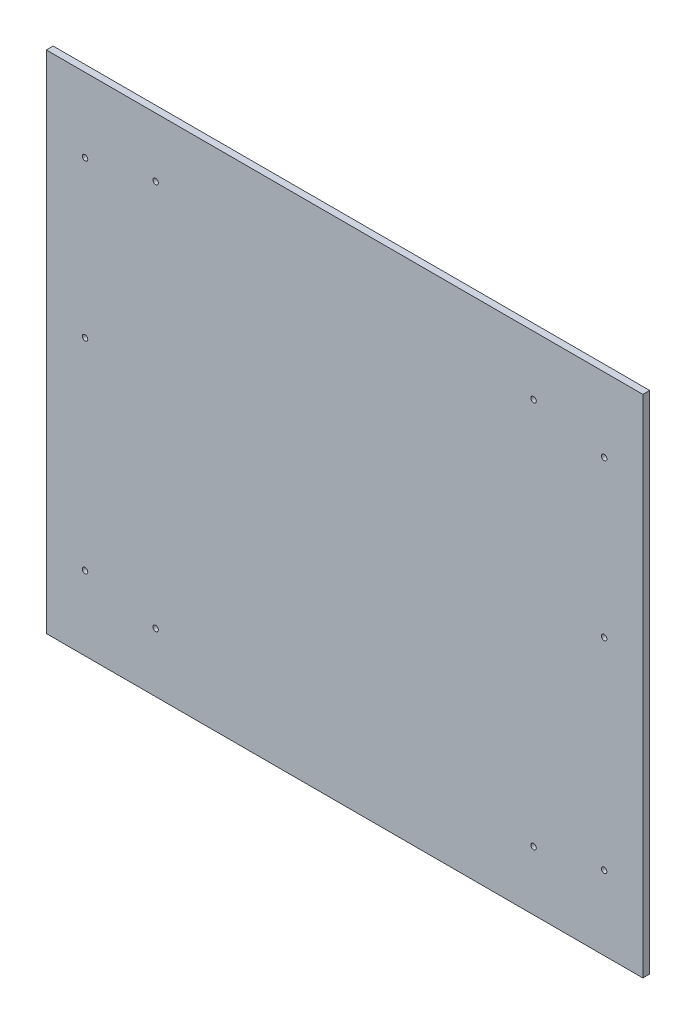
from build123d import *

# Parameters (mm, degrees)
SKETCH1_W           = 415.925
SKETCH1_H           = 352.425
BOSS_EXTRUDE1_DEPTH = 4.7625
SKETCH2_R           = 1.905
CUT_EXTRUDE1_DEPTH  = 546.178564927
SKETCH3_W           = 1.187532467
SKETCH3_H           = 0.445324675
CUT_EXTRUDE2_DEPTH  = 1.016


with BuildPart() as part:
    # Sketch1 → Boss-Extrude1 (new body)
    with BuildSketch(Plane.XY):
        with Locations((207.9625, 176.2125)):
            Rectangle(SKETCH1_W, SKETCH1_H)
    extrude(amount=BOSS_EXTRUDE1_DEPTH)

    # Sketch2 → Cut-Extrude1 (cut, through all)
    with BuildSketch(Plane.XY.offset(4.7625)):
        with Locations((26.9875, 300.8376)):
            Circle(SKETCH2_R)
        with Locations((76.2, 311.15)):
            Circle(SKETCH2_R)
        with Locations((339.725, 311.15)):
            Circle(SKETCH2_R)
        with Locations((388.9375, 300.8376)):
            Circle(SKETCH2_R)
        with Locations((388.9375, 51.5874)):
            Circle(SKETCH2_R)
        with Locations((339.725, 41.275)):
            Circle(SKETCH2_R)
        with Locations((76.2, 41.275)):
            Circle(SKETCH2_R)
        with Locations((26.9875, 51.5874)):
            Circle(SKETCH2_R)
        with Locations((388.9375, 192.1129)):
            Circle(SKETCH2_R)
        with Locations((26.9875, 192.1129)):
            Circle(SKETCH2_R)
    extrude(amount=-CUT_EXTRUDE1_DEPTH, mode=Mode.SUBTRACT)

    # Sketch3 → Cut-Extrude2 (cut)
    # profile 1 of 9: a face of its own
    with BuildSketch(Plane(origin=(0, 0, 0), x_dir=(-1, 0, 0), z_dir=(0, 0, -1))):
        with BuildLine():
            Line((-393.477337662, 342.759805195), (-393.477337662, 342.314480519))
            Line((-393.477337662, 342.314480519), (-395.506038961, 342.314480519))
            Line((-395.506038961, 342.314480519), (-395.506038961, 342.678626218))
            add(Edge.make_bspline(
                [(-395.506038961, 342.678626218), (-395.468398346, 342.729019781), (-395.391782626, 342.831593536), (-395.284642845, 342.995673671), (-395.180422941, 343.170411517), (-395.079134516, 343.35600437), (-394.981583276, 343.552757436), (-394.888439984, 343.760919034), (-394.798032534, 343.97984088), (-394.711299039, 344.207616848), (-394.630477833, 344.440759504), (-394.55861644, 344.675716266), (-394.49597565, 344.91044796), (-394.441784713, 345.144266238), (-394.39669102, 345.377624633), (-394.361230922, 345.610266071), (-394.33456031, 345.842641641), (-394.323851606, 345.997636362), (-394.318506494, 346.075)],
                knots=[0, 0, 0, 0, 0.828261285, 1.685887316, 2.579428271, 3.507501538, 4.469891598, 5.471065063, 6.510494938, 7.589089173, 8.680758398, 9.759817177, 10.82439165, 11.879940066, 12.920405774, 13.953938893, 14.978734705, 16, 16, 16, 16], degree=3))
            Line((-394.318506494, 346.075), (-393.922662338, 346.075))
            add(Edge.make_bspline(
                [(-393.922662338, 346.075), (-393.923986875, 346.034272503), (-393.926688347, 345.951206427), (-393.935072611, 345.824025376), (-393.949326583, 345.692062706), (-393.967885476, 345.55490528), (-393.991404903, 345.412963241), (-394.018115378, 345.265605514), (-394.050907603, 345.113622009), (-394.100262012, 344.904734731), (-394.17074871, 344.643569495), (-394.27199359, 344.335686313), (-394.386514382, 344.034985204), (-394.516465343, 343.744978733), (-394.653360159, 343.468424866), (-394.799935537, 343.212349388), (-394.947877923, 342.975021715), (-395.057095573, 342.830209652), (-395.110194805, 342.759805195)],
                knots=[0, 0, 0, 0, 0.547564817, 1.116789984, 1.712252562, 2.330831182, 2.976456312, 3.645516887, 4.343080939, 5.06547646, 6.529779861, 7.976466419, 9.419056042, 10.851576025, 12.245448489, 13.563727135, 14.815537433, 16, 16, 16, 16], degree=3))
            Line((-395.110194805, 342.759805195), (-393.477337662, 342.759805195))
        make_face()
    # profile 2 of 9: a face of its own
    with BuildSketch(Plane(origin=(0, 0, 0), x_dir=(-1, 0, 0), z_dir=(0, 0, -1))):
        with BuildLine():
            add(Edge.make_bspline(
                [(-391.052792208, 344.171546266), (-391.053420715, 344.093699787), (-391.054641124, 343.942540647), (-391.067256497, 343.723301933), (-391.087149192, 343.518482439), (-391.114218375, 343.328364953), (-391.150793557, 343.152893483), (-391.194120683, 342.991644432), (-391.246712232, 342.845069518), (-391.306601422, 342.713050189), (-391.374560688, 342.596099933), (-391.450819943, 342.494586722), (-391.534285551, 342.40767642), (-391.626667681, 342.337164287), (-391.726552425, 342.282486391), (-391.834148586, 342.243392942), (-391.949369475, 342.219741214), (-392.028889021, 342.216945789), (-392.069462256, 342.215519481)],
                knots=[0, 0, 0, 0, 1.522177082, 2.955701814, 4.292601031, 5.54555501, 6.7088804, 7.795771162, 8.808034672, 9.750647735, 10.627079958, 11.44753433, 12.228026558, 12.97593222, 13.711165822, 14.446140298, 15.20717461, 16, 16, 16, 16], degree=3))
            add(Edge.make_bspline(
                [(-392.069462256, 342.215519481), (-392.105642693, 342.216567003), (-392.176739531, 342.21862545), (-392.279973317, 342.239008477), (-392.377862811, 342.269394275), (-392.468984327, 342.314236048), (-392.55436888, 342.371331992), (-392.633001901, 342.441570068), (-392.706918017, 342.52345493), (-392.749005246, 342.585549567), (-392.770693994, 342.617548701)],
                knots=[0, 0, 0, 0, 1.02455918, 2.013323352, 2.972239719, 3.92313388, 4.881632631, 5.875512573, 6.905191138, 8, 8, 8, 8], degree=3))
            add(Edge.make_bspline(
                [(-392.770693994, 342.617548701), (-392.795879312, 342.660607774), (-392.848254839, 342.750153658), (-392.910673824, 342.900213857), (-392.963883516, 343.067875275), (-393.006388354, 343.253938447), (-393.04008333, 343.457665173), (-393.064541668, 343.679339462), (-393.079238458, 343.919303924), (-393.080723796, 344.085448953), (-393.081493506, 344.171546266)],
                knots=[0, 0, 0, 0, 0.745775943, 1.550919754, 2.425386613, 3.375801173, 4.404149056, 5.513981972, 6.711731112, 8, 8, 8, 8], degree=3))
            add(Edge.make_bspline(
                [(-393.081493506, 344.171546266), (-393.080870707, 344.24887833), (-393.079661616, 344.399009333), (-393.066960997, 344.616947571), (-393.047257801, 344.82077224), (-393.019650346, 345.010206705), (-392.984725408, 345.185471836), (-392.94047718, 345.346058322), (-392.889369572, 345.492789155), (-392.828997488, 345.624782088), (-392.761211678, 345.742244526), (-392.685557467, 345.84462891), (-392.600986329, 345.930654352), (-392.509487754, 346.002238222), (-392.408879891, 346.056674505), (-392.30130294, 346.096702061), (-392.185417991, 346.120268722), (-392.105649672, 346.123054653), (-392.064823458, 346.124480519)],
                knots=[0, 0, 0, 0, 1.513837482, 2.938935398, 4.272350439, 5.521752746, 6.68539866, 7.768673685, 8.780403913, 9.72410058, 10.605895827, 11.431327849, 12.209109083, 12.960945015, 13.697023823, 14.439318735, 15.201227913, 16, 16, 16, 16], degree=3))
            add(Edge.make_bspline(
                [(-392.064823458, 346.124480519), (-392.028403992, 346.123100238), (-391.956799224, 346.12038645), (-391.851879205, 346.100183178), (-391.752726503, 346.064299756), (-391.657719045, 346.016766518), (-391.56914014, 345.953425301), (-391.484609493, 345.878107789), (-391.40715652, 345.787206252), (-391.332347064, 345.683809362), (-391.265619672, 345.562527587), (-391.207827833, 345.422247349), (-391.159647217, 345.262123745), (-391.120897538, 345.082084112), (-391.090477628, 344.882476603), (-391.068271547, 344.663164253), (-391.055420146, 344.423999736), (-391.053691068, 344.257895447), (-391.052792208, 344.171546266)],
                knots=[0, 0, 0, 0, 0.713939269, 1.403684939, 2.084525483, 2.776045801, 3.479790818, 4.213328499, 4.990539752, 5.816442109, 6.712155869, 7.697513436, 8.78604652, 9.986360954, 11.305640346, 12.743160741, 14.306934742, 16, 16, 16, 16], degree=3))
        make_face()
        with BuildLine():
            add(Edge.make_bspline(
                [(-391.448636364, 344.17), (-391.449334298, 344.244225623), (-391.450669983, 344.386276111), (-391.457825727, 344.589758809), (-391.471645679, 344.773893567), (-391.490568084, 344.939050338), (-391.514886695, 345.085218557), (-391.544195101, 345.212688846), (-391.580159922, 345.320708809), (-391.621611944, 345.411166001), (-391.668282306, 345.486311397), (-391.716859016, 345.55110259), (-391.768812868, 345.60589696), (-391.824296426, 345.650465114), (-391.882579843, 345.68594172), (-391.944435843, 345.710881333), (-392.009437018, 345.726240174), (-392.053915462, 345.727831296), (-392.076420455, 345.728636364)],
                knots=[0, 0, 0, 0, 1.930680258, 3.694870612, 5.294765573, 6.732327541, 8.017244644, 9.14720992, 10.130763445, 10.973463911, 11.728776188, 12.427251247, 13.076760965, 13.687074849, 14.273357039, 14.844695938, 15.415444712, 16, 16, 16, 16], degree=3))
            add(Edge.make_bspline(
                [(-392.076420455, 345.728636364), (-392.097663352, 345.727905634), (-392.139961343, 345.726450636), (-392.201587006, 345.709676651), (-392.260921972, 345.685381714), (-392.316892401, 345.649190245), (-392.369934752, 345.603459923), (-392.420528422, 345.547719639), (-392.468395258, 345.482424333), (-392.514025281, 345.406248849), (-392.555919294, 345.315460741), (-392.590388363, 345.206521853), (-392.620440655, 345.079400574), (-392.643390255, 344.933536831), (-392.662751439, 344.769276411), (-392.676403618, 344.5861446), (-392.683621667, 344.384216791), (-392.684954074, 344.243453199), (-392.685649351, 344.17)],
                knots=[0, 0, 0, 0, 0.5561996, 1.107481919, 1.665324653, 2.233973471, 2.848122302, 3.499305928, 4.205575626, 4.970121907, 5.826722289, 6.823612291, 7.963984009, 9.252947287, 10.697030014, 12.304913753, 14.07183163, 16, 16, 16, 16], degree=3))
            add(Edge.make_bspline(
                [(-392.685649351, 344.17), (-392.684945534, 344.0957747), (-392.683596153, 343.953467315), (-392.67649858, 343.749723114), (-392.662578115, 343.565083176), (-392.643786994, 343.399651768), (-392.619387068, 343.253240013), (-392.590111314, 343.125751858), (-392.554066715, 343.017783878), (-392.512942511, 342.927370328), (-392.465679103, 342.852884787), (-392.41773459, 342.787852373), (-392.364395629, 342.734071922), (-392.308566737, 342.689729284), (-392.249994535, 342.653852032), (-392.187270103, 342.629006327), (-392.121215605, 342.6138322), (-392.075984688, 342.612189947), (-392.053226461, 342.611363636)],
                knots=[0, 0, 0, 0, 1.926017154, 3.692628624, 5.288659415, 6.729390826, 8.011204514, 9.138440624, 10.119618606, 10.960283728, 11.708082919, 12.404870975, 13.05267392, 13.666742433, 14.251608596, 14.827770794, 15.41018532, 16, 16, 16, 16], degree=3))
            add(Edge.make_bspline(
                [(-392.053226461, 342.611363636), (-392.031986838, 342.612089224), (-391.989945701, 342.613525433), (-391.928963675, 342.630097844), (-391.870589843, 342.655255423), (-391.814707213, 342.690327311), (-391.761810988, 342.735835512), (-391.71220374, 342.791553552), (-391.665200027, 342.857041397), (-391.619265594, 342.933118907), (-391.577807171, 343.024042424), (-391.543910549, 343.133052355), (-391.513988764, 343.260142847), (-391.489672903, 343.406071812), (-391.471925113, 343.570801974), (-391.457760773, 343.753840314), (-391.450698924, 343.955787546), (-391.449343599, 344.096548288), (-391.448636364, 344.17)],
                knots=[0, 0, 0, 0, 0.557130238, 1.102768586, 1.649079731, 2.224414864, 2.830037934, 3.477754783, 4.181203309, 4.947028836, 5.811221183, 6.801235864, 7.943515661, 9.242435973, 10.688157038, 12.298731102, 14.068605401, 16, 16, 16, 16], degree=3))
        make_face(mode=Mode.SUBTRACT)
    # profile 3 of 9: a face of its own
    with BuildSketch(Plane(origin=(0, 0, 0), x_dir=(-1, 0, 0), z_dir=(0, 0, -1))):
        with BuildLine():
            Line((-390.607467532, 343.155649351), (-390.211623377, 343.20512987))
            add(Edge.make_bspline(
                [(-390.211623377, 343.20512987), (-390.202473465, 343.160047347), (-390.18533987, 343.075628425), (-390.148177301, 342.961267534), (-390.106771331, 342.865650808), (-390.06848073, 342.814915331), (-390.050811688, 342.791503653)],
                knots=[0, 0, 0, 0, 1.230211225, 2.30362229, 3.217213433, 4, 4, 4, 4], degree=3))
            add(Edge.make_bspline(
                [(-390.050811688, 342.791503653), (-390.037964368, 342.777036853), (-390.012983773, 342.748907309), (-389.971432824, 342.712528789), (-389.928595753, 342.680818907), (-389.883275657, 342.655665045), (-389.835878281, 342.635707963), (-389.786480356, 342.622120171), (-389.735171455, 342.613252157), (-389.700361104, 342.611996884), (-389.682800325, 342.611363636)],
                knots=[0, 0, 0, 0, 1.095058468, 2.129254274, 3.122126386, 4.109077278, 5.058043602, 6.028662132, 7.005519128, 8, 8, 8, 8], degree=3))
            add(Edge.make_bspline(
                [(-389.682800325, 342.611363636), (-389.655598097, 342.612372919), (-389.601705009, 342.614372511), (-389.523494826, 342.635930105), (-389.449038837, 342.668299898), (-389.37937846, 342.715115777), (-389.314380823, 342.774722044), (-389.252662681, 342.846556458), (-389.196545262, 342.932267966), (-389.163968139, 342.995292364), (-389.147019075, 343.028082386)],
                knots=[0, 0, 0, 0, 0.906800098, 1.796553483, 2.691003266, 3.610512055, 4.585978966, 5.630213089, 6.767058994, 8, 8, 8, 8], degree=3))
            add(Edge.make_bspline(
                [(-389.147019075, 343.028082386), (-389.132799324, 343.059556936), (-389.103236151, 343.124993211), (-389.068465249, 343.231608912), (-389.038363557, 343.348595762), (-389.01390063, 343.476443857), (-388.994820575, 343.614775065), (-388.981076185, 343.763880324), (-388.97256513, 343.923529559), (-388.971363472, 344.0336599), (-388.970744724, 344.090367289)],
                knots=[0, 0, 0, 0, 0.763483597, 1.587299063, 2.476320726, 3.434428227, 4.464721063, 5.564015708, 6.745683445, 8, 8, 8, 8], degree=3))
            add(Edge.make_bspline(
                [(-388.970744724, 344.090367289), (-388.993158545, 344.051779011), (-389.036771466, 343.976693756), (-389.118029618, 343.878306448), (-389.205455101, 343.79233399), (-389.302259572, 343.723353909), (-389.404047822, 343.668441578), (-389.50978088, 343.629813192), (-389.618545827, 343.605332156), (-389.692208711, 343.602430627), (-389.729188312, 343.600974026)],
                knots=[0, 0, 0, 0, 1.127755568, 2.194392168, 3.218534893, 4.223278226, 5.192146243, 6.137338825, 7.064923014, 8, 8, 8, 8], degree=3))
            add(Edge.make_bspline(
                [(-389.729188312, 343.600974026), (-389.75992013, 343.602043049), (-389.820490571, 343.604150025), (-389.90987178, 343.620095148), (-389.99591496, 343.646611326), (-390.079418744, 343.683078595), (-390.159553132, 343.731036133), (-390.236886956, 343.788971217), (-390.310449804, 343.858081598), (-390.381529738, 343.935353982), (-390.446055146, 344.022397267), (-390.502649131, 344.117222812), (-390.550941798, 344.21883731), (-390.589271134, 344.328140412), (-390.620350571, 344.443832774), (-390.641924268, 344.5669682), (-390.65401193, 344.697032236), (-390.655953734, 344.786162167), (-390.656948052, 344.831801948)],
                knots=[0, 0, 0, 0, 0.860357646, 1.695709716, 2.533583491, 3.377064945, 4.241047709, 5.143225219, 6.077846286, 7.063889573, 8.080111547, 9.106229702, 10.152257742, 11.225204373, 12.345649275, 13.503769734, 14.721782881, 16, 16, 16, 16], degree=3))
            add(Edge.make_bspline(
                [(-390.656948052, 344.831801948), (-390.655369388, 344.89373845), (-390.652276956, 345.015065396), (-390.626365287, 345.192708364), (-390.582723351, 345.361211421), (-390.533307712, 345.494785347), (-390.485731891, 345.594847636), (-390.4480047, 345.664679758), (-390.40725726, 345.729164645), (-390.365468799, 345.789405203), (-390.320067428, 345.844098086), (-390.272324328, 345.893255741), (-390.222449939, 345.938050469), (-390.152831441, 345.989902018), (-390.061307575, 346.044189556), (-389.944067702, 346.090198598), (-389.82183566, 346.1192935), (-389.738111138, 346.122743127), (-389.695943588, 346.124480519)],
                knots=[0, 0, 0, 0, 1.657477552, 3.246820249, 4.792931373, 6.310143579, 7.050773408, 7.757735392, 8.433441671, 9.091881484, 9.719037924, 10.333777231, 10.92503469, 11.511442381, 12.655601843, 13.761194519, 14.872433761, 16, 16, 16, 16], degree=3))
            add(Edge.make_bspline(
                [(-389.695943588, 346.124480519), (-389.657965638, 346.123146599), (-389.583268517, 346.120522971), (-389.473909496, 346.099631205), (-389.369639244, 346.066474311), (-389.270306014, 346.019449958), (-389.176171081, 345.958701956), (-389.088046229, 345.8837132), (-389.004711431, 345.796088497), (-388.925998233, 345.695381479), (-388.855254814, 345.577964477), (-388.79341898, 345.443485106), (-388.74218369, 345.290663853), (-388.699961774, 345.120530549), (-388.668302501, 344.932285776), (-388.64435944, 344.726919625), (-388.630712108, 344.503405603), (-388.629089694, 344.348612267), (-388.628246753, 344.268187906)],
                knots=[0, 0, 0, 0, 0.760776034, 1.496336177, 2.223302797, 2.948873241, 3.69253306, 4.462409234, 5.262555392, 6.112948448, 7.019240997, 8.003827252, 9.073820409, 10.245244624, 11.514025169, 12.897394376, 14.388011526, 16, 16, 16, 16], degree=3))
            add(Edge.make_bspline(
                [(-388.628246753, 344.268187906), (-388.628981258, 344.178995628), (-388.630396168, 344.007180526), (-388.645498674, 343.759302982), (-388.668514021, 343.531328334), (-388.702260558, 343.32314478), (-388.745820755, 343.134944384), (-388.799020458, 342.966265342), (-388.860516465, 342.816764507), (-388.93423961, 342.68772789), (-389.015147646, 342.576880529), (-389.100674292, 342.480235194), (-389.192114975, 342.398909838), (-389.288544539, 342.330888216), (-389.39187051, 342.279924332), (-389.499970775, 342.242078823), (-389.614150271, 342.220215171), (-389.691987696, 342.21710075), (-389.731507711, 342.215519481)],
                knots=[0, 0, 0, 0, 1.648984134, 3.176512383, 4.589967025, 5.884119787, 7.073476536, 8.158525833, 9.151516126, 10.056402341, 10.89896907, 11.685273886, 12.437938781, 13.157016243, 13.860256991, 14.560990922, 15.269378972, 16, 16, 16, 16], degree=3))
            add(Edge.make_bspline(
                [(-389.731507711, 342.215519481), (-389.760140715, 342.216334396), (-389.81658196, 342.217940754), (-389.899618949, 342.228485779), (-389.978735295, 342.248164491), (-390.05423745, 342.274715315), (-390.1268353, 342.307590736), (-390.194813376, 342.350210592), (-390.26027686, 342.398759894), (-390.321123847, 342.455520163), (-390.378192013, 342.518803058), (-390.427936776, 342.590527443), (-390.473122626, 342.667889199), (-390.511880671, 342.752389342), (-390.545009644, 342.843394079), (-390.571761818, 342.941484558), (-390.593855608, 343.045981089), (-390.602850737, 343.118452853), (-390.607467532, 343.155649351)],
                knots=[0, 0, 0, 0, 0.965270463, 1.902736681, 2.815070868, 3.708007483, 4.598108228, 5.495050481, 6.40721921, 7.341661662, 8.295409263, 9.273996573, 10.278274954, 11.312175679, 12.403221606, 13.539269482, 14.737017652, 16, 16, 16, 16], degree=3))
        make_face()
        with BuildLine():
            add(Edge.make_bspline(
                [(-389.024090909, 344.817112419), (-389.024658095, 344.850635702), (-389.025764218, 344.916012686), (-389.035153868, 345.011634583), (-389.050840271, 345.102205589), (-389.070906812, 345.188154757), (-389.099238897, 345.268481961), (-389.133493704, 345.343541033), (-389.17248878, 345.414651166), (-389.219208881, 345.478852972), (-389.268608373, 345.537306851), (-389.321089963, 345.587766945), (-389.374095679, 345.631938641), (-389.430656472, 345.666674389), (-389.48859196, 345.695261546), (-389.549403591, 345.714256462), (-389.61169681, 345.726465359), (-389.653879746, 345.727910462), (-389.675068994, 345.728636364)],
                knots=[0, 0, 0, 0, 1.296144346, 2.527735915, 3.710626612, 4.84906567, 5.936415351, 6.997883046, 8.037465384, 9.066195934, 10.06280824, 10.993087436, 11.878683343, 12.724822989, 13.553888704, 14.370157937, 15.181301027, 16, 16, 16, 16], degree=3))
            add(Edge.make_bspline(
                [(-389.675068994, 345.728636364), (-389.693925955, 345.727824191), (-389.7314327, 345.72620877), (-389.78674129, 345.715337564), (-389.839978825, 345.696059271), (-389.892157517, 345.67061852), (-389.942659641, 345.636897131), (-389.99131128, 345.59557911), (-390.038463566, 345.547293741), (-390.084210532, 345.492757042), (-390.125411859, 345.431223911), (-390.162209104, 345.364094771), (-390.193174133, 345.291365281), (-390.21738709, 345.212664185), (-390.238001663, 345.128906633), (-390.251513396, 345.039377239), (-390.259062051, 344.944295118), (-390.260409666, 344.879234596), (-390.261103896, 344.845718344)],
                knots=[0, 0, 0, 0, 0.772526166, 1.536564769, 2.297899578, 3.086420588, 3.909253034, 4.7784632, 5.696750295, 6.671391525, 7.690425714, 8.72514537, 9.803697274, 10.922277634, 12.095098258, 13.334461535, 14.626834596, 16, 16, 16, 16], degree=3))
            add(Edge.make_bspline(
                [(-390.261103896, 344.845718344), (-390.260412361, 344.812974454), (-390.259070891, 344.749456403), (-390.251497997, 344.656692466), (-390.238116789, 344.569698862), (-390.217297902, 344.488559428), (-390.193168303, 344.412771686), (-390.162919753, 344.34240948), (-390.126330267, 344.278080098), (-390.084971331, 344.219423722), (-390.038882645, 344.167855557), (-389.991418487, 344.121423918), (-389.939599906, 344.083741173), (-389.886664096, 344.051534661), (-389.830580818, 344.027486013), (-389.772438817, 344.009167282), (-389.711210827, 343.999463874), (-389.669685652, 343.997704051), (-389.648782468, 343.996818182)],
                knots=[0, 0, 0, 0, 1.344260104, 2.607655456, 3.818208625, 4.95233668, 6.042998368, 7.080704521, 8.089811597, 9.076145914, 10.020627392, 10.926084953, 11.795728431, 12.644859331, 13.464478827, 14.294411822, 15.14143111, 16, 16, 16, 16], degree=3))
            add(Edge.make_bspline(
                [(-389.648782468, 343.996818182), (-389.628107721, 343.997249999), (-389.587232524, 343.998103727), (-389.52744012, 344.009822359), (-389.469119735, 344.026651267), (-389.413219254, 344.051509021), (-389.35910561, 344.082940854), (-389.30715603, 344.120907458), (-389.257583479, 344.166385393), (-389.209800935, 344.217741885), (-389.166020167, 344.275301239), (-389.127587227, 344.338395433), (-389.096714625, 344.40686728), (-389.068557718, 344.478931254), (-389.049216249, 344.556977772), (-389.034398547, 344.639333892), (-389.025955371, 344.726740339), (-389.024723966, 344.786427587), (-389.024090909, 344.817112419)],
                knots=[0, 0, 0, 0, 0.863254972, 1.706706166, 2.538719029, 3.397725308, 4.257272268, 5.151846783, 6.082689542, 7.066491316, 8.081726413, 9.101982937, 10.148262134, 11.219173362, 12.332727134, 13.503929281, 14.716786026, 16, 16, 16, 16], degree=3))
        make_face(mode=Mode.SUBTRACT)
    # profile 4 of 9: a face of its own
    with BuildSketch(Plane(origin=(0, 0, 0), x_dir=(-1, 0, 0), z_dir=(0, 0, -1))):
        with Locations((-387.737597403, 344.714285715)):
            Rectangle(SKETCH3_W, SKETCH3_H)
    # profile 5 of 9: a face of its own
    with BuildSketch(Plane(origin=(0, 0, 0), x_dir=(-1, 0, 0), z_dir=(0, 0, -1))):
        with BuildLine():
            Line((-384.422402597, 346.075), (-384.422402597, 342.265))
            Line((-384.422402597, 342.265), (-385.596018669, 342.265))
            add(Edge.make_bspline(
                [(-385.596018669, 342.265), (-385.629528361, 342.264967122), (-385.693996001, 342.264903869), (-385.787272264, 342.269486529), (-385.873745587, 342.274019261), (-385.953583162, 342.283112428), (-386.026671742, 342.292614608), (-386.093103244, 342.304847397), (-386.152429123, 342.320182023), (-386.189330738, 342.332580342), (-386.206793831, 342.338447646)],
                knots=[0, 0, 0, 0, 1.301151554, 2.5032211, 3.626367283, 4.663111316, 5.622785769, 6.488454062, 7.284685336, 8, 8, 8, 8], degree=3))
            add(Edge.make_bspline(
                [(-386.206793831, 342.338447646), (-386.228906778, 342.347006422), (-386.273080272, 342.364103693), (-386.335299039, 342.397858945), (-386.394659917, 342.435880865), (-386.450449654, 342.47919156), (-386.502494578, 342.528339334), (-386.55098663, 342.582662641), (-386.597272071, 342.641539723), (-386.638489308, 342.706626788), (-386.676305244, 342.775675377), (-386.709191652, 342.848992032), (-386.735922453, 342.926509397), (-386.758192899, 343.007628667), (-386.776410473, 343.092479295), (-386.788143288, 343.181166043), (-386.796466352, 343.273780541), (-386.797128733, 343.336800264), (-386.797467532, 343.369034091)],
                knots=[0, 0, 0, 0, 0.896949636, 1.791773796, 2.674115289, 3.564138569, 4.461512697, 5.380431273, 6.319235066, 7.293620624, 8.293517089, 9.298115845, 10.331907158, 11.394805857, 12.481795972, 13.614719922, 14.779958068, 16, 16, 16, 16], degree=3))
            add(Edge.make_bspline(
                [(-386.797467532, 343.369034091), (-386.796813064, 343.411329133), (-386.795533078, 343.494048314), (-386.782965582, 343.615035218), (-386.762078809, 343.729747989), (-386.733581034, 343.838737713), (-386.69656993, 343.941839797), (-386.650739821, 344.038783306), (-386.596975716, 344.129915425), (-386.535596254, 344.215406195), (-386.463266447, 344.293223419), (-386.377903141, 344.359795485), (-386.281322129, 344.416732086), (-386.172317742, 344.461987776), (-386.052001893, 344.498542139), (-385.919283808, 344.52346175), (-385.774676288, 344.537894822), (-385.674397369, 344.540006787), (-385.622305195, 344.541103896)],
                knots=[0, 0, 0, 0, 1.066125632, 2.085091685, 3.062630143, 4.003547869, 4.922307223, 5.820454748, 6.703048758, 7.586837887, 8.469431897, 9.371589709, 10.306565591, 11.287746888, 12.340181319, 13.471797101, 14.68666727, 16, 16, 16, 16], degree=3))
            Line((-385.622305195, 344.541103896), (-384.818246753, 344.541103896))
            Line((-384.818246753, 344.541103896), (-384.818246753, 346.075))
            Line((-384.818246753, 346.075), (-384.422402597, 346.075))
        make_face()
        with BuildLine():
            Line((-384.818246753, 344.095779221), (-385.647045455, 344.095779221))
            add(Edge.make_bspline(
                [(-385.647045455, 344.095779221), (-385.678497922, 344.095072553), (-385.739437411, 344.093703376), (-385.827888777, 344.086401224), (-385.90981958, 344.072472093), (-385.985207163, 344.053403979), (-386.053828531, 344.028515848), (-386.116393252, 343.998512377), (-386.172010809, 343.962057606), (-386.221449173, 343.920660111), (-386.264731189, 343.873859832), (-386.300681822, 343.820382937), (-386.333132875, 343.762699455), (-386.357110427, 343.698235357), (-386.377777731, 343.629448083), (-386.391181192, 343.554488089), (-386.399832405, 343.474126569), (-386.401014524, 343.41853911), (-386.401623377, 343.389908685)],
                knots=[0, 0, 0, 0, 1.269253369, 2.459191891, 3.57717208, 4.618751137, 5.592406951, 6.51784041, 7.411898102, 8.267961587, 9.11430795, 9.973837676, 10.862619214, 11.777890835, 12.742005423, 13.757621058, 14.845058537, 16, 16, 16, 16], degree=3))
            add(Edge.make_bspline(
                [(-386.401623377, 343.389908685), (-386.400765806, 343.352718312), (-386.399112226, 343.281007281), (-386.381273378, 343.177539277), (-386.354190387, 343.082180593), (-386.315244634, 342.996077246), (-386.268571331, 342.920992201), (-386.216780718, 342.85717429), (-386.159474957, 342.806928238), (-386.107164851, 342.774014782), (-386.059934659, 342.75559541), (-386.018549051, 342.743364254), (-385.970874141, 342.732297917), (-385.916408282, 342.725562987), (-385.856206146, 342.717951432), (-385.78959763, 342.713934261), (-385.716664451, 342.710456778), (-385.665863933, 342.710370018), (-385.639314123, 342.710324675)],
                knots=[0, 0, 0, 0, 1.499931441, 2.892190131, 4.22555523, 5.492142586, 6.693106624, 7.786754549, 8.796791062, 9.758519433, 10.262760139, 10.83874575, 11.500028322, 12.235695527, 13.052584314, 13.949495096, 14.928347241, 16, 16, 16, 16], degree=3))
            Line((-385.639314123, 342.710324675), (-384.818246753, 342.710324675))
            Line((-384.818246753, 342.710324675), (-384.818246753, 344.095779221))
        make_face(mode=Mode.SUBTRACT)
    # profile 6 of 9: a face of its own
    with BuildSketch(Plane(origin=(0, 0, 0), x_dir=(-1, 0, 0), z_dir=(0, 0, -1))):
        Polygon((-381.156688312, 346.075), (-382.373599838, 342.265), (-382.759393263, 342.265), (-383.977077922, 346.075), (-383.565771104, 346.075), (-383.232550731, 344.936948052), (-381.901215503, 344.936948052), (-381.568768263, 346.075), align=None)
        with BuildLine():
            Line((-382.031101867, 344.491623377), (-383.101891234, 344.491623377))
            Line((-383.101891234, 344.491623377), (-382.78336039, 343.444801136))
            add(Edge.make_bspline(
                [(-382.78336039, 343.444801136), (-382.771453681, 343.405644679), (-382.748207569, 343.329197404), (-382.715129304, 343.21729957), (-382.683955834, 343.110936062), (-382.65533931, 343.010238171), (-382.630030958, 342.915013068), (-382.606510676, 342.825668444), (-382.585807712, 342.741862712), (-382.573024068, 342.687656588), (-382.566883117, 342.661617289)],
                knots=[0, 0, 0, 0, 1.208585302, 2.359586633, 3.44573617, 4.481694954, 5.45087266, 6.355352717, 7.20995158, 8, 8, 8, 8], degree=3))
            add(Edge.make_bspline(
                [(-382.566883117, 342.661617289), (-382.555744256, 342.722273282), (-382.533481332, 342.843504692), (-382.491750358, 343.024101348), (-382.445323383, 343.204372112), (-382.408369221, 343.323303121), (-382.389835633, 343.382950487)],
                knots=[0, 0, 0, 0, 0.995500629, 1.989678841, 2.991765375, 4, 4, 4, 4], degree=3))
            Line((-382.389835633, 343.382950487), (-382.031101867, 344.491623377))
        make_face(mode=Mode.SUBTRACT)
    # profile 7 of 9: a face of its own
    with BuildSketch(Plane(origin=(0, 0, 0), x_dir=(-1, 0, 0), z_dir=(0, 0, -1))):
        with BuildLine():
            Line((-378.48474026, 344.837987013), (-378.880584416, 344.788506494))
            add(Edge.make_bspline(
                [(-378.880584416, 344.788506494), (-378.886331949, 344.838909793), (-378.897232191, 344.934500036), (-378.927375084, 345.068226035), (-378.966719786, 345.184773275), (-379.018287855, 345.28458693), (-379.079638996, 345.371843245), (-379.153468329, 345.447986007), (-379.238303741, 345.515742898), (-379.334324107, 345.573399638), (-379.439064368, 345.620510736), (-379.551214922, 345.654703711), (-379.669977541, 345.675195853), (-379.751308181, 345.677816343), (-379.792881494, 345.679155844)],
                knots=[0, 0, 0, 0, 1.281050936, 2.429522926, 3.457180855, 4.380419844, 5.258532054, 6.142803829, 7.050969554, 7.994650731, 8.965267996, 9.945773918, 10.949953137, 12, 12, 12, 12], degree=3))
            add(Edge.make_bspline(
                [(-379.792881494, 345.679155844), (-379.822541993, 345.678551244), (-379.880184758, 345.677376254), (-379.964132031, 345.668590543), (-380.043154489, 345.65522932), (-380.11704238, 345.634800624), (-380.185965753, 345.60946668), (-380.250032468, 345.578655904), (-380.308243586, 345.540984603), (-380.361663357, 345.498827459), (-380.408656662, 345.451460857), (-380.449980828, 345.401053944), (-380.485116262, 345.347224949), (-380.514167218, 345.289812303), (-380.535093274, 345.228424141), (-380.552092735, 345.164513952), (-380.56117095, 345.09673265), (-380.56232922, 345.050364796), (-380.562922078, 345.026631494)],
                knots=[0, 0, 0, 0, 1.2501121, 2.429491015, 3.554738234, 4.624770363, 5.655989494, 6.647174221, 7.614555715, 8.573174125, 9.51037654, 10.421526264, 11.316469507, 12.215294815, 13.125861444, 14.045456575, 14.999570494, 16, 16, 16, 16], degree=3))
            add(Edge.make_bspline(
                [(-380.562922078, 345.026631494), (-380.562093559, 344.999248947), (-380.560479806, 344.945914399), (-380.546074433, 344.868469165), (-380.523189486, 344.796259476), (-380.49031881, 344.729360381), (-380.447165385, 344.668665642), (-380.394779616, 344.61334418), (-380.333193812, 344.563694586), (-380.273638854, 344.526945624), (-380.216658564, 344.499761383), (-380.16221683, 344.477732576), (-380.097383711, 344.452893541), (-380.021297497, 344.426673176), (-379.934322719, 344.399178774), (-379.836314384, 344.369778314), (-379.727646163, 344.338012805), (-379.651173182, 344.317037002), (-379.611195211, 344.306071429)],
                knots=[0, 0, 0, 0, 1.004942946, 1.957384713, 2.882338134, 3.779759916, 4.683151972, 5.607184727, 6.569546081, 7.580932032, 8.169390295, 8.886581061, 9.73741851, 10.719272822, 11.841835979, 13.087539982, 14.477446005, 16, 16, 16, 16], degree=3))
            add(Edge.make_bspline(
                [(-379.611195211, 344.306071429), (-379.575320658, 344.295941638), (-379.506184865, 344.27641997), (-379.406996258, 344.24529218), (-379.315565666, 344.214594735), (-379.232093159, 344.183259157), (-379.15736306, 344.15052746), (-379.090162914, 344.119087896), (-379.031161023, 344.086722516), (-378.96387237, 344.042833056), (-378.889733026, 343.983265141), (-378.810642346, 343.904209616), (-378.743289932, 343.815103053), (-378.685793505, 343.71831831), (-378.639751145, 343.613563122), (-378.607741291, 343.501182058), (-378.586638412, 343.382454082), (-378.584692647, 343.300833878), (-378.583701299, 343.259249188)],
                knots=[0, 0, 0, 0, 1.11410023, 2.147042836, 3.106741435, 3.996541296, 4.810716634, 5.544561419, 6.213395996, 6.820137826, 7.943677056, 9.049331341, 10.153911915, 11.272794625, 12.407604075, 13.562982632, 14.758363689, 16, 16, 16, 16], degree=3))
            add(Edge.make_bspline(
                [(-378.583701299, 343.259249188), (-378.584554506, 343.221834289), (-378.58623174, 343.148284137), (-378.600551928, 343.040634776), (-378.623245723, 342.93784847), (-378.657126135, 342.841036619), (-378.698519511, 342.748770908), (-378.751264074, 342.662908573), (-378.811479304, 342.580910179), (-378.881702253, 342.505639879), (-378.959844213, 342.437724684), (-379.044456104, 342.377527533), (-379.136176272, 342.327326958), (-379.234330312, 342.286038827), (-379.339064607, 342.254434224), (-379.450174059, 342.23245445), (-379.567518156, 342.217934003), (-379.648002592, 342.216338028), (-379.689281656, 342.215519481)],
                knots=[0, 0, 0, 0, 1.048393069, 2.060929513, 3.038830284, 3.993780679, 4.931247035, 5.867877984, 6.812802159, 7.778917813, 8.746652657, 9.710740501, 10.683960439, 11.671447009, 12.69068745, 13.744764791, 14.843329183, 16, 16, 16, 16], degree=3))
            add(Edge.make_bspline(
                [(-379.689281656, 342.215519481), (-379.745580106, 342.216974054), (-379.85547477, 342.219813383), (-380.014420722, 342.247072837), (-380.163141882, 342.28894095), (-380.299791863, 342.34975518), (-380.424063793, 342.425954172), (-380.533579505, 342.518610955), (-380.629162845, 342.625476588), (-380.7085522, 342.747792513), (-380.773254265, 342.882493334), (-380.818821159, 343.029819188), (-380.851137198, 343.187556419), (-380.856863126, 343.297223053), (-380.859805195, 343.353571429)],
                knots=[0, 0, 0, 0, 1.103087042, 2.153227681, 3.152832388, 4.125700178, 5.076543329, 6.001835811, 6.928906841, 7.877827614, 8.852072615, 9.849362458, 10.894969883, 12, 12, 12, 12], degree=3))
            Line((-380.859805195, 343.353571429), (-380.463961039, 343.403051948))
            add(Edge.make_bspline(
                [(-380.463961039, 343.403051948), (-380.46105924, 343.372583303), (-380.455400509, 343.313167092), (-380.439726545, 343.22770974), (-380.419825564, 343.147973811), (-380.394454545, 343.074759533), (-380.364162144, 343.007320512), (-380.328561363, 342.946245636), (-380.288302112, 342.890662824), (-380.24238098, 342.841816502), (-380.191520018, 342.798790369), (-380.135798692, 342.761598477), (-380.074914846, 342.73067466), (-380.009641626, 342.70516999), (-379.939836018, 342.684873199), (-379.864950836, 342.671310266), (-379.78535236, 342.662663116), (-379.730538885, 342.661460818), (-379.702424919, 342.660844156)],
                knots=[0, 0, 0, 0, 1.224567217, 2.388000622, 3.473802986, 4.511193751, 5.485264017, 6.428251882, 7.336054882, 8.226401348, 9.104715552, 9.997329813, 10.901550796, 11.832500991, 12.798839329, 13.80636261, 14.874877956, 16, 16, 16, 16], degree=3))
            add(Edge.make_bspline(
                [(-379.702424919, 342.660844156), (-379.673790609, 342.66109803), (-379.618444384, 342.661588733), (-379.538167367, 342.67079473), (-379.46288067, 342.683536196), (-379.392575155, 342.701704158), (-379.327901443, 342.726254294), (-379.267674525, 342.754305957), (-379.213642034, 342.789569222), (-379.164455839, 342.829011482), (-379.12138807, 342.873294968), (-379.083366278, 342.920274786), (-379.051160464, 342.970537883), (-379.024744013, 343.023880828), (-379.004805194, 343.080841869), (-378.989884925, 343.140575874), (-378.981455248, 343.203602014), (-378.980190519, 343.246597373), (-378.979545455, 343.268526786)],
                knots=[0, 0, 0, 0, 1.287208177, 2.487998315, 3.629583546, 4.720547933, 5.747622748, 6.737928225, 7.702594599, 8.642209589, 9.568501139, 10.475514979, 11.356601253, 12.248299753, 13.14660463, 14.065979384, 15.013569424, 16, 16, 16, 16], degree=3))
            add(Edge.make_bspline(
                [(-378.979545455, 343.268526786), (-378.980896558, 343.307825673), (-378.983474276, 343.382802481), (-379.006350711, 343.48825036), (-379.045708148, 343.580324487), (-379.084867248, 343.630535324), (-379.104019886, 343.655093344)],
                knots=[0, 0, 0, 0, 1.13496852, 2.165362018, 3.1026822, 4, 4, 4, 4], degree=3))
            add(Edge.make_bspline(
                [(-379.104019886, 343.655093344), (-379.115796846, 343.66683712), (-379.141375788, 343.692343991), (-379.190639956, 343.724479958), (-379.249281236, 343.758288056), (-379.320346584, 343.788950833), (-379.40124602, 343.821101615), (-379.494022124, 343.85057774), (-379.597498215, 343.881075779), (-379.670902875, 343.899186823), (-379.709383117, 343.908681006)],
                knots=[0, 0, 0, 0, 0.600125557, 1.303441474, 2.117395318, 3.047759802, 4.098473224, 5.265768101, 6.566659033, 8, 8, 8, 8], degree=3))
            add(Edge.make_bspline(
                [(-379.709383117, 343.908681006), (-379.747303609, 343.91781368), (-379.82016778, 343.935362098), (-379.92459242, 343.962967146), (-380.020595912, 343.987617332), (-380.10731976, 344.013976206), (-380.186016856, 344.037113892), (-380.25558559, 344.060890894), (-380.316998798, 344.08158186), (-380.354006172, 344.097614457), (-380.371185065, 344.105056818)],
                knots=[0, 0, 0, 0, 1.354627537, 2.602914845, 3.751427062, 4.796509307, 5.750709438, 6.599842999, 7.350044479, 8, 8, 8, 8], degree=3))
            add(Edge.make_bspline(
                [(-380.371185065, 344.105056818), (-380.417260521, 344.127502653), (-380.507109136, 344.171272751), (-380.626643162, 344.256449902), (-380.729182129, 344.353454816), (-380.813352322, 344.463246505), (-380.879107524, 344.585427375), (-380.925318657, 344.719073568), (-380.953865053, 344.863582363), (-380.957102204, 344.963614068), (-380.958766234, 345.015034497)],
                knots=[0, 0, 0, 0, 1.065737589, 2.078222431, 3.042321546, 3.99544048, 4.946245188, 5.9187461, 6.930149531, 8, 8, 8, 8], degree=3))
            add(Edge.make_bspline(
                [(-380.958766234, 345.015034497), (-380.95707824, 345.066707845), (-380.953742919, 345.168809627), (-380.924347317, 345.318216586), (-380.875852937, 345.460249565), (-380.809769769, 345.593988973), (-380.726023991, 345.715632083), (-380.629486212, 345.824672043), (-380.516795276, 345.915825579), (-380.391645837, 345.992126292), (-380.252480692, 346.052141625), (-380.099769699, 346.094098216), (-379.933704934, 346.12008471), (-379.818495271, 346.122981278), (-379.758863636, 346.124480519)],
                knots=[0, 0, 0, 0, 1.011388709, 1.998411015, 2.968967368, 3.944198793, 4.910281663, 5.85392204, 6.786589481, 7.738015058, 8.7170017, 9.744598853, 10.832621746, 12, 12, 12, 12], degree=3))
            add(Edge.make_bspline(
                [(-379.758863636, 346.124480519), (-379.711912043, 346.123493181), (-379.620292146, 346.121566519), (-379.486754623, 346.105062203), (-379.360465347, 346.077955706), (-379.241369999, 346.040480889), (-379.129368976, 345.99121329), (-379.025107814, 345.930768495), (-378.927610861, 345.860133544), (-378.838765894, 345.778622801), (-378.758421575, 345.688252571), (-378.687465711, 345.589767707), (-378.628149419, 345.482728939), (-378.577039106, 345.369069334), (-378.539334524, 345.246748562), (-378.509299256, 345.117706686), (-378.490938072, 344.980478121), (-378.486838697, 344.886231234), (-378.48474026, 344.837987013)],
                knots=[0, 0, 0, 0, 1.105125728, 2.15650842, 3.162144254, 4.142719577, 5.090863706, 6.036889248, 6.975040306, 7.919917109, 8.869748829, 9.817737626, 10.77130242, 11.746550588, 12.746311686, 13.779592379, 14.863391239, 16, 16, 16, 16], degree=3))
        make_face()
    # profile 8 of 9: a face of its own
    with BuildSketch(Plane(origin=(0, 0, 0), x_dir=(-1, 0, 0), z_dir=(0, 0, -1))):
        with BuildLine():
            Line((-377.643571429, 344.739025974), (-378.039415584, 344.837987013))
            add(Edge.make_bspline(
                [(-378.039415584, 344.837987013), (-378.027619304, 344.890444651), (-378.00462148, 344.992715161), (-377.961451554, 345.139796591), (-377.911130857, 345.276362215), (-377.854552982, 345.402532807), (-377.793202786, 345.519248417), (-377.724044217, 345.625101636), (-377.648032988, 345.720206996), (-377.56673575, 345.806133921), (-377.479136724, 345.880752473), (-377.387447095, 345.946651223), (-377.290402323, 346.001589899), (-377.188842372, 346.046487735), (-377.08297794, 346.081673744), (-376.972328695, 346.106020795), (-376.857264567, 346.122316435), (-376.778750294, 346.123753211), (-376.739005682, 346.124480519)],
                knots=[0, 0, 0, 0, 1.28922044, 2.513442024, 3.673007215, 4.776830106, 5.827500731, 6.832022649, 7.803999827, 8.743849815, 9.66425458, 10.559455276, 11.447931646, 12.33337188, 13.21872583, 14.118353182, 15.047493909, 16, 16, 16, 16], degree=3))
            add(Edge.make_bspline(
                [(-376.739005682, 346.124480519), (-376.70392784, 346.123995589), (-376.635167039, 346.123045011), (-376.533970419, 346.112332084), (-376.436442536, 346.09661846), (-376.342946554, 346.073259685), (-376.253163552, 346.043802616), (-376.167586062, 346.007552215), (-376.085628848, 345.964618092), (-376.007398528, 345.915151129), (-375.932712576, 345.858183371), (-375.861188863, 345.793928145), (-375.794053492, 345.720889528), (-375.730568482, 345.640006539), (-375.670319117, 345.551573701), (-375.612765015, 345.455530476), (-375.559879991, 345.350811787), (-375.509823264, 345.239216786), (-375.463702449, 345.121146566), (-375.425810371, 344.996539203), (-375.39254646, 344.867303545), (-375.364191732, 344.73304812), (-375.343805358, 344.593304002), (-375.329378571, 344.448304039), (-375.319636997, 344.298214418), (-375.318543157, 344.196302164), (-375.317987013, 344.144486607)],
                knots=[0, 0, 0, 0, 0.921121005, 1.8056133, 2.67040233, 3.514377161, 4.334332635, 5.150394009, 5.952862848, 6.762354685, 7.578837179, 8.417691682, 9.284809544, 10.181422086, 11.116567612, 12.094173645, 13.120585634, 14.196358798, 15.306518391, 16.447844343, 17.615314784, 18.811617913, 20.050550251, 21.323062097, 22.638956355, 24, 24, 24, 24], degree=3))
            add(Edge.make_bspline(
                [(-375.317987013, 344.144486607), (-375.318529789, 344.09344224), (-375.319594342, 343.993328321), (-375.329446342, 343.846347954), (-375.343382829, 343.705083291), (-375.365487812, 343.570005761), (-375.392121532, 343.440575203), (-375.42537875, 343.317405906), (-375.464856625, 343.200166064), (-375.510386484, 343.089279045), (-375.560758312, 342.984477494), (-375.61564374, 342.886026725), (-375.674929626, 342.794445185), (-375.73816589, 342.708976145), (-375.805684098, 342.630485333), (-375.878217083, 342.558766661), (-375.954912977, 342.493904017), (-376.035237605, 342.434781854), (-376.119398141, 342.3835315), (-376.205673836, 342.338020905), (-376.294709761, 342.300258732), (-376.38618202, 342.269228138), (-376.480001922, 342.245107118), (-376.57620489, 342.228522759), (-376.674548635, 342.2168254), (-376.741032394, 342.215957359), (-376.774569805, 342.215519481)],
                knots=[0, 0, 0, 0, 1.355095116, 2.65776402, 3.909870136, 5.122541271, 6.290068247, 7.417112276, 8.507673222, 9.572493115, 10.597729848, 11.593310423, 12.563163512, 13.492386605, 14.414173163, 15.309288628, 16.197683675, 17.079068066, 17.954536164, 18.811491617, 19.666833809, 20.519379772, 21.374064851, 22.235787637, 23.110051606, 24, 24, 24, 24], degree=3))
            add(Edge.make_bspline(
                [(-376.774569805, 342.215519481), (-376.81120022, 342.21645987), (-376.883154787, 342.218307114), (-376.989388084, 342.231464185), (-377.091270603, 342.254790035), (-377.189479914, 342.286879451), (-377.284087939, 342.32668686), (-377.374370751, 342.377019385), (-377.461175641, 342.435540364), (-377.543000684, 342.504156986), (-377.620728845, 342.580202205), (-377.690933885, 342.666584693), (-377.757240972, 342.759677722), (-377.815289001, 342.862622137), (-377.869671317, 342.972570109), (-377.914693313, 343.09226598), (-377.957839852, 343.219139094), (-377.979057013, 343.308008188), (-377.989935065, 343.353571429)],
                knots=[0, 0, 0, 0, 0.969148585, 1.903736758, 2.826785899, 3.730310196, 4.634631807, 5.538027439, 6.460975827, 7.40040228, 8.359931585, 9.333412464, 10.34173472, 11.380359485, 12.456904674, 13.583902902, 14.761265506, 16, 16, 16, 16], degree=3))
            Line((-377.989935065, 343.353571429), (-377.594090909, 343.452532468))
            add(Edge.make_bspline(
                [(-377.594090909, 343.452532468), (-377.585144025, 343.420475961), (-377.567694912, 343.357956141), (-377.536643723, 343.268158622), (-377.502682264, 343.184492228), (-377.465772695, 343.106731073), (-377.424670898, 343.035549928), (-377.380578168, 342.97036873), (-377.333419035, 342.911006022), (-377.282202957, 342.858713519), (-377.228634476, 342.811531073), (-377.171072085, 342.77111196), (-377.109993718, 342.737345532), (-377.045951307, 342.708960738), (-376.97874247, 342.68761031), (-376.908146209, 342.67188415), (-376.834350166, 342.662608057), (-376.78387324, 342.661436776), (-376.75833401, 342.660844156)],
                knots=[0, 0, 0, 0, 1.274827499, 2.486296693, 3.637698816, 4.732866786, 5.781146847, 6.783409552, 7.745577291, 8.681189198, 9.583979081, 10.476943643, 11.369744444, 12.253932728, 13.156290603, 14.066553906, 15.021756508, 16, 16, 16, 16], degree=3))
            add(Edge.make_bspline(
                [(-376.75833401, 342.660844156), (-376.707928057, 342.662721365), (-376.609568485, 342.666384453), (-376.467490249, 342.696514712), (-376.335505576, 342.745356445), (-376.234958324, 342.803351856), (-376.16021161, 342.85911977), (-376.107295402, 342.907109928), (-376.056698269, 342.959889492), (-376.009160351, 343.018178924), (-375.965711418, 343.082646901), (-375.923272495, 343.151583631), (-375.885253426, 343.226587521), (-375.84911136, 343.306531129), (-375.817751109, 343.392422684), (-375.789967788, 343.483805768), (-375.765916773, 343.580516823), (-375.746666363, 343.682746847), (-375.732325488, 343.790404515), (-375.721276849, 343.903590273), (-375.715342389, 344.022267783), (-375.714341091, 344.103247017), (-375.713831169, 344.144486607)],
                knots=[0, 0, 0, 0, 1.477319852, 2.882765608, 4.239071619, 5.5901645, 6.270494264, 6.971711204, 7.682800365, 8.413585745, 9.174705695, 9.961627353, 10.786552627, 11.639271465, 12.533754274, 13.466330389, 14.439856922, 15.455412122, 16.515914326, 17.624622774, 18.79031228, 20, 20, 20, 20], degree=3))
            add(Edge.make_bspline(
                [(-375.713831169, 344.144486607), (-375.714819381, 344.206354355), (-375.716736092, 344.326351419), (-375.72868849, 344.500664004), (-375.750327095, 344.663040141), (-375.779738515, 344.813671297), (-375.819665247, 344.951715604), (-375.865986308, 345.078574397), (-375.922839506, 345.192956316), (-375.987661392, 345.295323925), (-376.060019047, 345.385564294), (-376.138080892, 345.464189612), (-376.222348657, 345.530394192), (-376.311796583, 345.58544152), (-376.4077571, 345.627078534), (-376.508882685, 345.657535292), (-376.615949019, 345.675602538), (-376.689198389, 345.677954021), (-376.726635552, 345.679155844)],
                knots=[0, 0, 0, 0, 1.437065497, 2.787294602, 4.055458609, 5.239956664, 6.348318907, 7.390106744, 8.372560959, 9.309120415, 10.199089469, 11.054089278, 11.876775321, 12.682652122, 13.486748469, 14.299179022, 15.1307241, 16, 16, 16, 16], degree=3))
            add(Edge.make_bspline(
                [(-376.726635552, 345.679155844), (-376.754506367, 345.678389674), (-376.809428852, 345.676879851), (-376.890396061, 345.665591376), (-376.968726888, 345.648163196), (-377.044156943, 345.622486255), (-377.116235422, 345.588943367), (-377.185363018, 345.548579054), (-377.251575916, 345.500900365), (-377.314750039, 345.446346454), (-377.373943042, 345.384057289), (-377.428081404, 345.313996154), (-377.477673751, 345.236859265), (-377.520877953, 345.151607577), (-377.55951017, 345.059325244), (-377.59350094, 344.95941217), (-377.622142805, 344.851942635), (-377.636313692, 344.777270121), (-377.643571429, 344.739025974)],
                knots=[0, 0, 0, 0, 0.928238582, 1.829195527, 2.718541612, 3.598220604, 4.477899596, 5.362883569, 6.261136532, 7.192387853, 8.139765768, 9.118675424, 10.13801499, 11.190128329, 12.298336808, 13.468533125, 14.703488264, 16, 16, 16, 16], degree=3))
        make_face()
    # profile 9 of 9: a face of its own
    with BuildSketch(Plane(origin=(0, 0, 0), x_dir=(-1, 0, 0), z_dir=(0, 0, -1))):
        Polygon((-372.992402597, 346.075), (-372.992402597, 342.265), (-373.388246753, 342.265), (-373.388246753, 345.629675325), (-374.971623377, 345.629675325), (-374.971623377, 346.075), align=None)
    extrude(amount=-CUT_EXTRUDE2_DEPTH, mode=Mode.SUBTRACT)


solid = part.part
